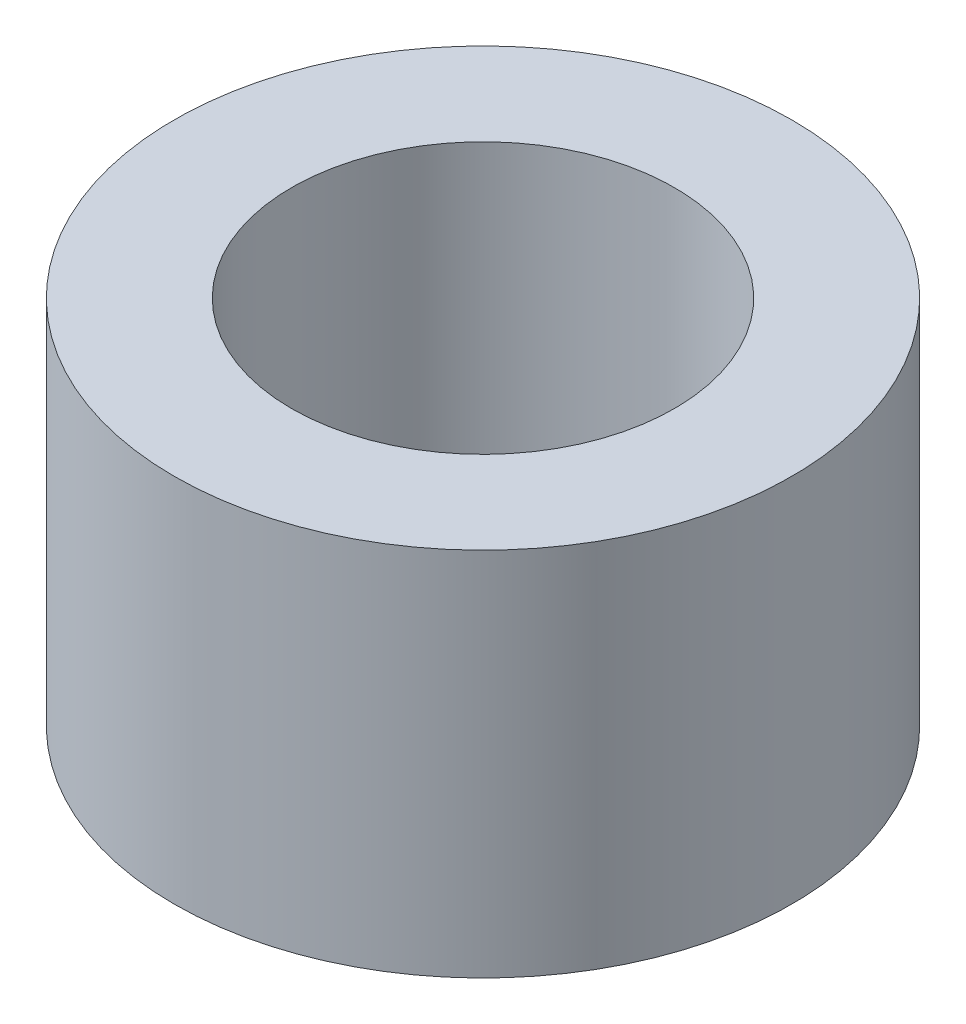
from build123d import *

# Parameters (mm, degrees)
SKETCH_1_R      = 2.5
SKETCH_1_R_2    = 1.55
EXTRUDE_1_DEPTH = 3


with BuildPart() as part:
    # 草图1 → 凸台-拉伸1 (new body)
    with BuildSketch(Plane(origin=(0, 0, 0), x_dir=(1, 0, 0), z_dir=(0, 1, 0))):
        Circle(SKETCH_1_R)
        Circle(SKETCH_1_R_2, mode=Mode.SUBTRACT)
    extrude(amount=EXTRUDE_1_DEPTH)


solid = part.part
